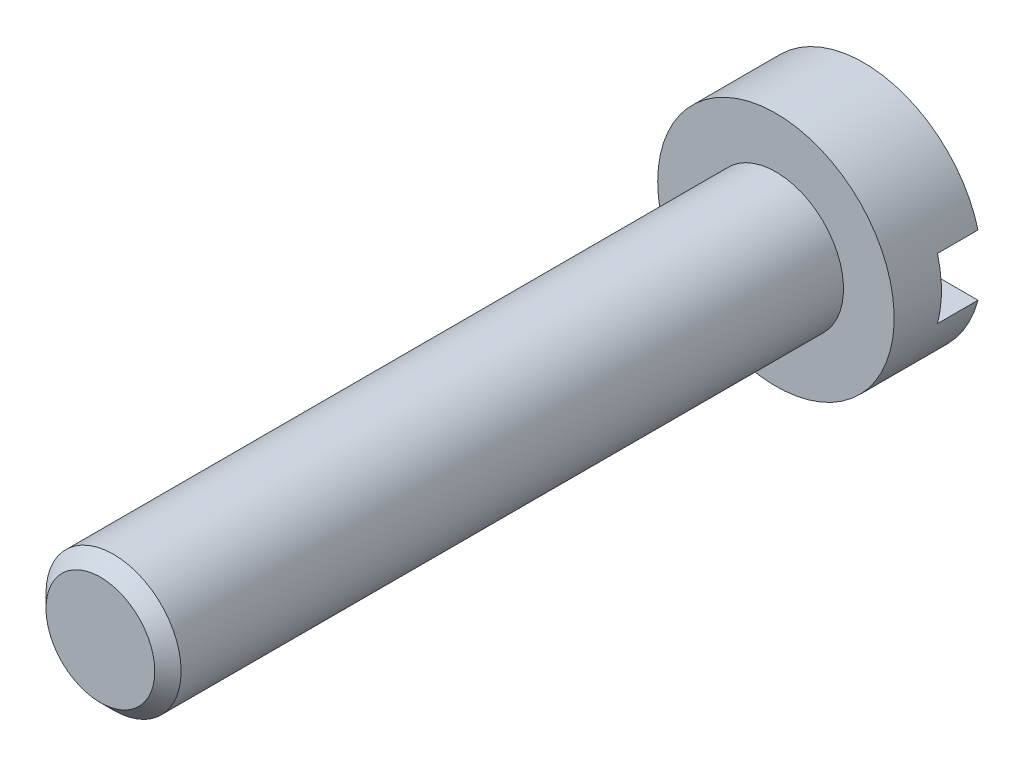
from build123d import *

# Parameters (mm, degrees)
SKETCH_1_R          = 2
EXTRUDE_1_DEPTH     = 20
SKETCH_2_R          = 3.5
EXTRUDE_2_DEPTH     = 2.6
SKETCH_3_W          = 9
SKETCH_3_H          = 1.8
CUT_EXTRUDE_1_DEPTH = 1.2
CHAMFER_1_SIZE      = 0.39


with BuildPart() as part:
    # Эскиз1 → Бобышка-Вытянуть1 (new body)
    with BuildSketch(Plane.XY):
        Circle(SKETCH_1_R)
    extrude(amount=EXTRUDE_1_DEPTH)

    # Эскиз2 → Бобышка-Вытянуть2 (add)
    with BuildSketch(Plane(origin=(0, 0, 0), x_dir=(-1, 0, 0), z_dir=(0, 0, -1))):
        Circle(SKETCH_2_R)
    extrude(amount=EXTRUDE_2_DEPTH)

    # Эскиз3 → Вырез-Вытянуть1 (cut)
    with BuildSketch(Plane(origin=(0, 0, -2.6), x_dir=(-1, 0, 0), z_dir=(0, 0, -1))):
        Rectangle(SKETCH_3_W, SKETCH_3_H)
    extrude(amount=-CUT_EXTRUDE_1_DEPTH, mode=Mode.SUBTRACT)

    # Фаска1
    chamfer_1_edges = [part.edges().sort_by_distance(p)[0] for p in [
        (-2, 0, 20),
    ]]
    chamfer(chamfer_1_edges, length=CHAMFER_1_SIZE)


solid = part.part
